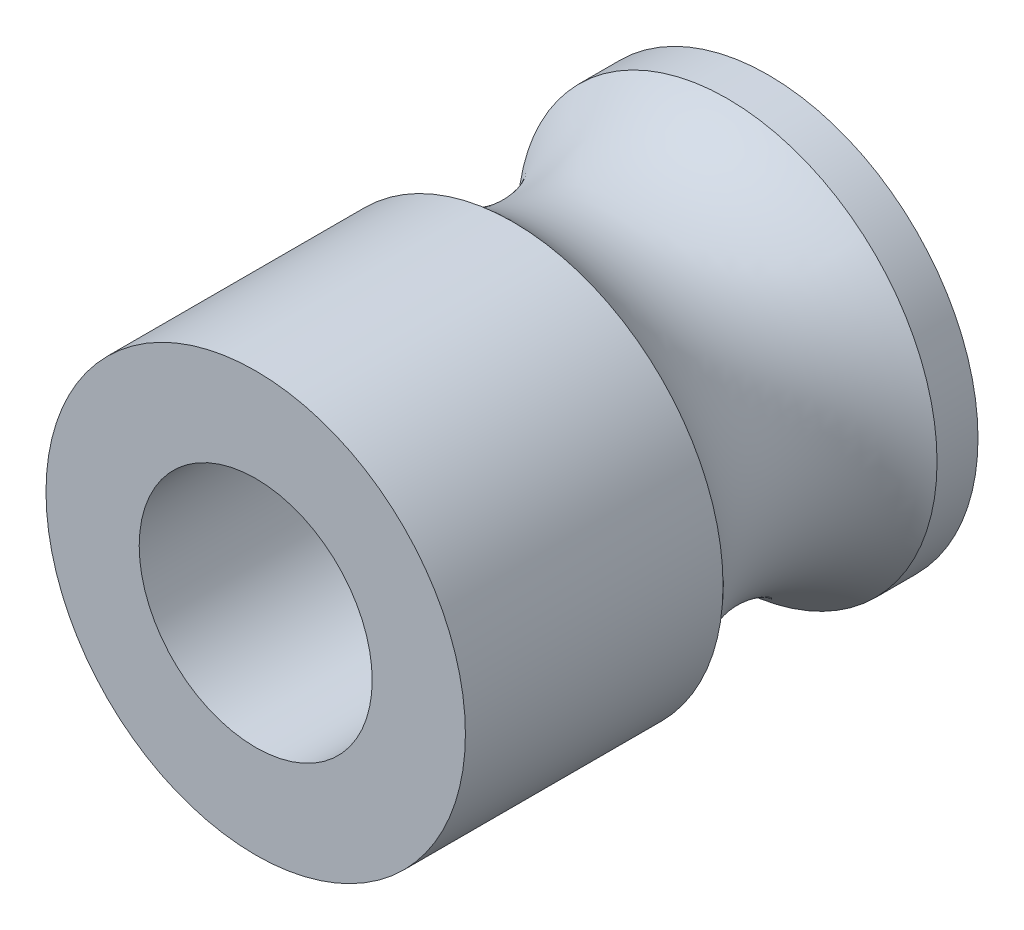
from build123d import *

# Parameters (mm, degrees)
F_5_0_5_DIAMETER_HOLE1_D     = 5
F_5_0_5_DIAMETER_HOLE1_DEPTH = 11


with BuildPart() as part:
    # Sketch1 → Revolve1 (revolve)
    with BuildSketch(Plane(origin=(0, 0, 0), x_dir=(1, 0, 0), z_dir=(0, 1, 0))):
        with BuildLine():
            Line((4.5, 0), (0, 0))
            Line((0, 0), (0, -11))
            Line((0, -11), (4.5, -11))
            Line((4.5, -11), (4.5, -5.471192501))
            ThreePointArc((4.5, -5.471192501), (3.55, -3.175), (4.5, -0.878807499))
            Line((4.5, -0.878807499), (4.5, 0))
        make_face()
    revolve(axis=Axis((0, 0, 0), (0, 0, 1)))

    # Ø5.0 (5) Diameter Hole1
    with Locations(Plane.XY.offset(11)):
        with Locations((0, 0)):
            Hole(F_5_0_5_DIAMETER_HOLE1_D / 2, depth=F_5_0_5_DIAMETER_HOLE1_DEPTH)


solid = part.part
